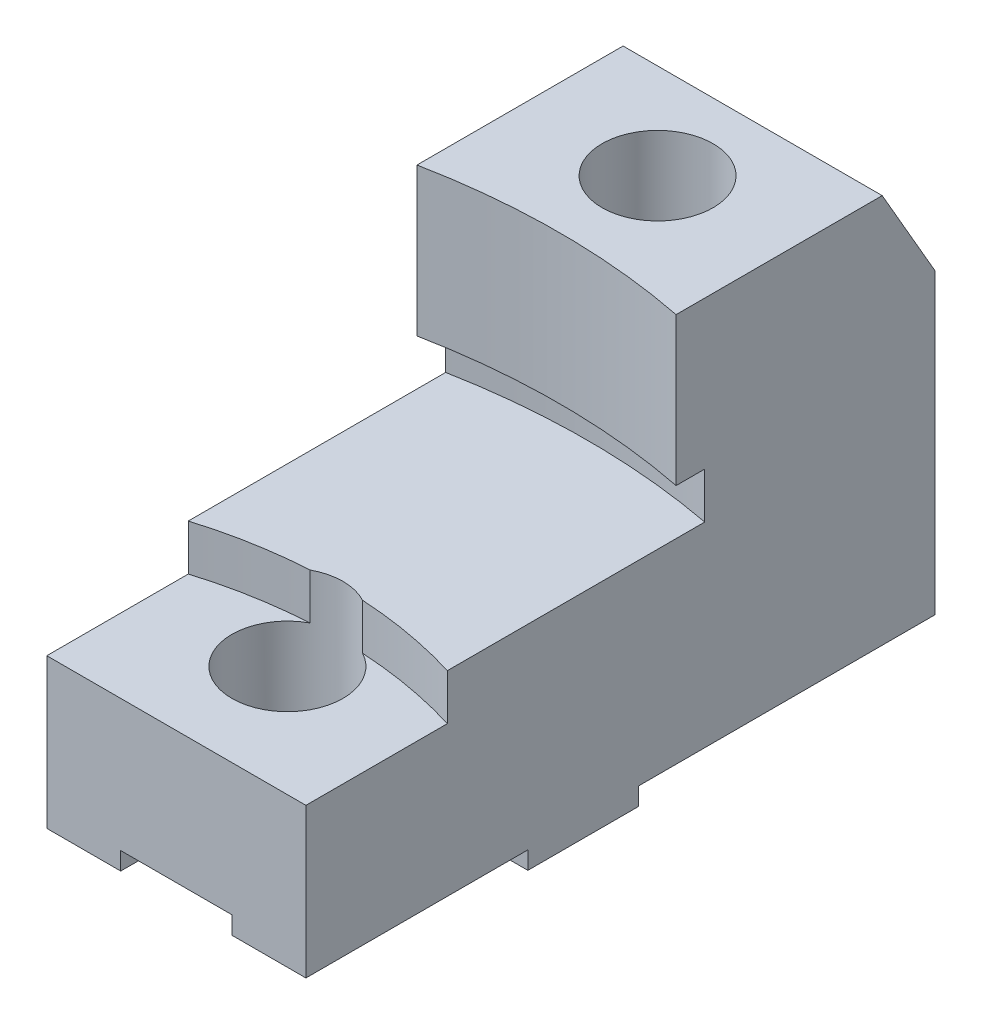
from build123d import *

# Parameters (mm, degrees)
SKETCH1_W                = 1.75
SKETCH1_H                = 4.25
EXTRUDE1_DEPTH           = 2.75
SKETCH3_W                = 2.0025
SKETCH3_H                = 0.12
CUT_EXTRUDE1_DEPTH       = 2.75
SKETCH4_W                = 1.499
SKETCH4_H                = 0.12
CUT_EXTRUDE2_DEPTH       = 2.75
SKETCH5_W                = 0.7515
SKETCH5_H                = 0.24
CUT_EXTRUDE3_DEPTH       = 5.25
CUT_EXTRUDE4_DEPTH       = 1.31
CUT_EXTRUDE7_START       = -1
CUT_EXTRUDE7_DEPTH       = 0.31
CUT_EXTRUDE8_DEPTH       = 0.31
SKETCH11_R               = 0.375
CUT_EXTRUDE10_DEPTH      = 2.62
CUT_EXTRUDE10_DEPTH_BACK = 0.81
SKETCH13_R               = 0.25
CUT_EXTRUDE11_DEPTH      = 0.81
SKETCH14_R               = 0.375
SKETCH14_R_2             = 0.25
CUT_EXTRUDE12_DEPTH      = 0.81
SKETCH15_R               = 0.25
CUT_EXTRUDE13_DEPTH      = 2.94
CUT_EXTRUDE14_DEPTH      = 2.75


with BuildPart() as part:
    # Sketch1 → Extrude1 (new body)
    with BuildSketch(Plane(origin=(0, 0, 0), x_dir=(1, 0, 0), z_dir=(0, 1, 0))):
        with Locations((-0.587019269, 0.04717902)):
            Rectangle(SKETCH1_W, SKETCH1_H)
    extrude(amount=EXTRUDE1_DEPTH)

    # Sketch3 → Cut-Extrude1 (cut)
    with BuildSketch(Plane.ZY.offset(1.462019269)):
        with Locations((-1.17092902, 0.06)):
            Rectangle(SKETCH3_W, SKETCH3_H)
    extrude(amount=-CUT_EXTRUDE1_DEPTH, mode=Mode.SUBTRACT)

    # Sketch4 → Cut-Extrude2 (cut)
    with BuildSketch(Plane.ZY.offset(1.462019269)):
        with Locations((1.32832098, 0.06)):
            Rectangle(SKETCH4_W, SKETCH4_H)
    extrude(amount=-CUT_EXTRUDE2_DEPTH, mode=Mode.SUBTRACT)

    # Sketch5 → Cut-Extrude3 (cut, through all)
    with BuildSketch(Plane.XY.offset(2.07782098)):
        with Locations((-0.587019269, 0.12)):
            Rectangle(SKETCH5_W, SKETCH5_H)
    extrude(amount=-CUT_EXTRUDE3_DEPTH, mode=Mode.SUBTRACT)

    # Sketch6 → Cut-Extrude4 (cut)
    with BuildSketch(Plane(origin=(0, 2.75, 0), x_dir=(-1, 0, 0), z_dir=(0, 1, 0))):
        with BuildLine():
            ThreePointArc((-0.287980731, -0.42217902), (0.587019269, -0.508068124), (1.462019269, -0.42217902))
            Line((1.462019269, -0.42217902), (1.462019269, 2.07782098))
            Line((1.462019269, 2.07782098), (-0.287980731, 2.07782098))
            Line((-0.287980731, 2.07782098), (-0.287980731, -0.42217902))
        make_face()
    extrude(amount=-CUT_EXTRUDE4_DEPTH, mode=Mode.SUBTRACT)

    # Sketch7 → Cut-Extrude7 (cut)
    with BuildSketch(Plane(origin=(0, 2.75, 0), x_dir=(-1, 0, 0), z_dir=(0, 1, 0)).offset(CUT_EXTRUDE7_START)):
        with BuildLine():
            Line((1.462019269, -0.615722082), (1.462019269, -0.42217902))
            ThreePointArc((1.462019269, -0.42217902), (0.587019269, -0.508068124), (-0.287980731, -0.42217902))
            Line((-0.287980731, -0.42217902), (-0.287980731, -0.615722082))
            ThreePointArc((-0.287980731, -0.615722082), (0.587019269, -0.698068124), (1.462019269, -0.615722082))
        make_face()
    extrude(amount=-CUT_EXTRUDE7_DEPTH, mode=Mode.SUBTRACT)

    # Sketch8 → Cut-Extrude8 (cut)
    with BuildSketch(Plane(origin=(0, 1.44, 0), x_dir=(-1, 0, 0), z_dir=(0, 1, 0))):
        with BuildLine():
            ThreePointArc((-0.287980731, 1.122371805), (0.587019269, 0.991931876), (1.462019269, 1.122371805))
            Line((1.462019269, 1.122371805), (1.462019269, 2.07782098))
            Line((1.462019269, 2.07782098), (-0.287980731, 2.07782098))
            Line((-0.287980731, 2.07782098), (-0.287980731, 1.122371805))
        make_face()
    extrude(amount=-CUT_EXTRUDE8_DEPTH, mode=Mode.SUBTRACT)

    # Sketch11 → Cut-Extrude10 (cut, two sides)
    with BuildSketch(Plane(origin=(0, 1.13, 0), x_dir=(-1, 0, 0), z_dir=(0, 1, 0))) as cut_extrude10_sk:
        with Locations((0.587019269, 1.32782098)):
            Circle(SKETCH11_R)
    extrude(amount=CUT_EXTRUDE10_DEPTH, mode=Mode.SUBTRACT)
    extrude(cut_extrude10_sk.sketch, amount=-CUT_EXTRUDE10_DEPTH_BACK, mode=Mode.SUBTRACT)

    # Sketch13 → Cut-Extrude11 (cut)
    with BuildSketch(Plane(origin=(0, 0.32, 0), x_dir=(-1, 0, 0), z_dir=(0, 1, 0))):
        with Locations((0.587019269, 1.32782098)):
            Circle(SKETCH13_R)
    extrude(amount=-CUT_EXTRUDE11_DEPTH, mode=Mode.SUBTRACT)

    # Sketch14 → Cut-Extrude12 (cut)
    with BuildSketch(Plane(origin=(0, 2.75, 0), x_dir=(-1, 0, 0), z_dir=(0, 1, 0))):
        with Locations((0.587019269, -1.17217902)):
            Circle(SKETCH14_R)
        with Locations((0.587019269, 1.32782098)):
            Circle(SKETCH14_R_2)
    extrude(amount=-CUT_EXTRUDE12_DEPTH, mode=Mode.SUBTRACT)

    # Sketch15 → Cut-Extrude13 (cut, through all)
    with BuildSketch(Plane(origin=(0, 1.94, 0), x_dir=(-1, 0, 0), z_dir=(0, 1, 0))):
        with Locations((0.587019269, -1.17217902)):
            Circle(SKETCH15_R)
    extrude(amount=-CUT_EXTRUDE13_DEPTH, mode=Mode.SUBTRACT)

    # Sketch16 → Cut-Extrude14 (cut, through all)
    with BuildSketch(Plane.ZY.offset(1.462019269)):
        Polygon((-2.17217902, 2.75), (-2.17217902, 2.13), (-1.814221853, 2.75), align=None)
    extrude(amount=-CUT_EXTRUDE14_DEPTH, mode=Mode.SUBTRACT)


solid = part.part
